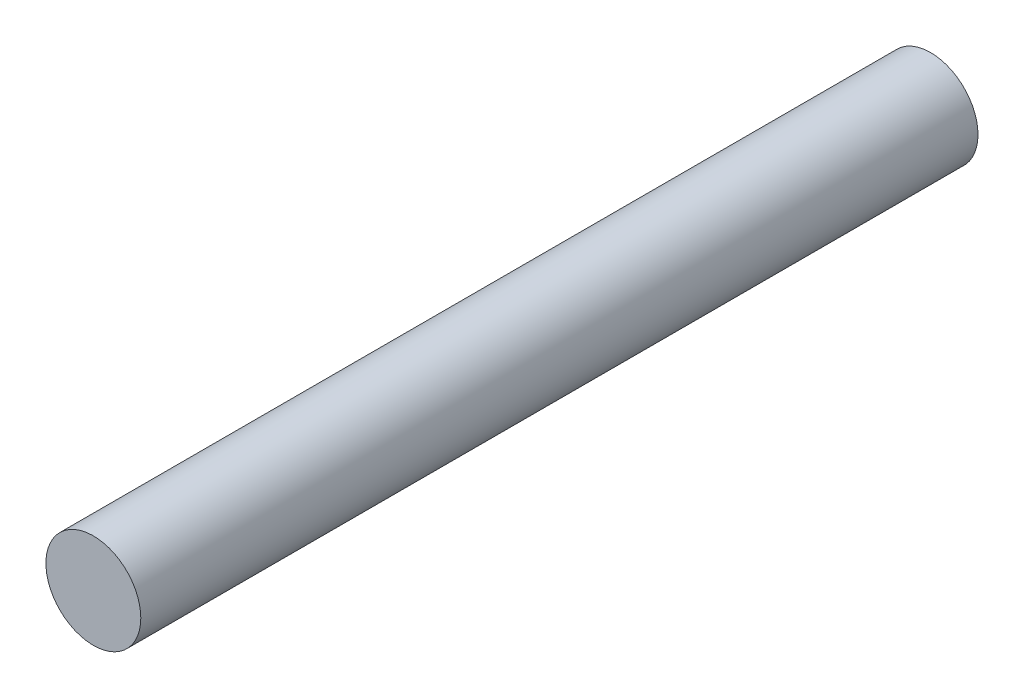
from build123d import *

# Parameters (mm, degrees)
SKETCH1_R           = 4.25
BOSS_EXTRUDE1_DEPTH = 75


with BuildPart() as part:
    # Sketch1 → Boss-Extrude1 (new body)
    with BuildSketch(Plane.XY):
        Circle(SKETCH1_R)
    extrude(amount=BOSS_EXTRUDE1_DEPTH)


solid = part.part
